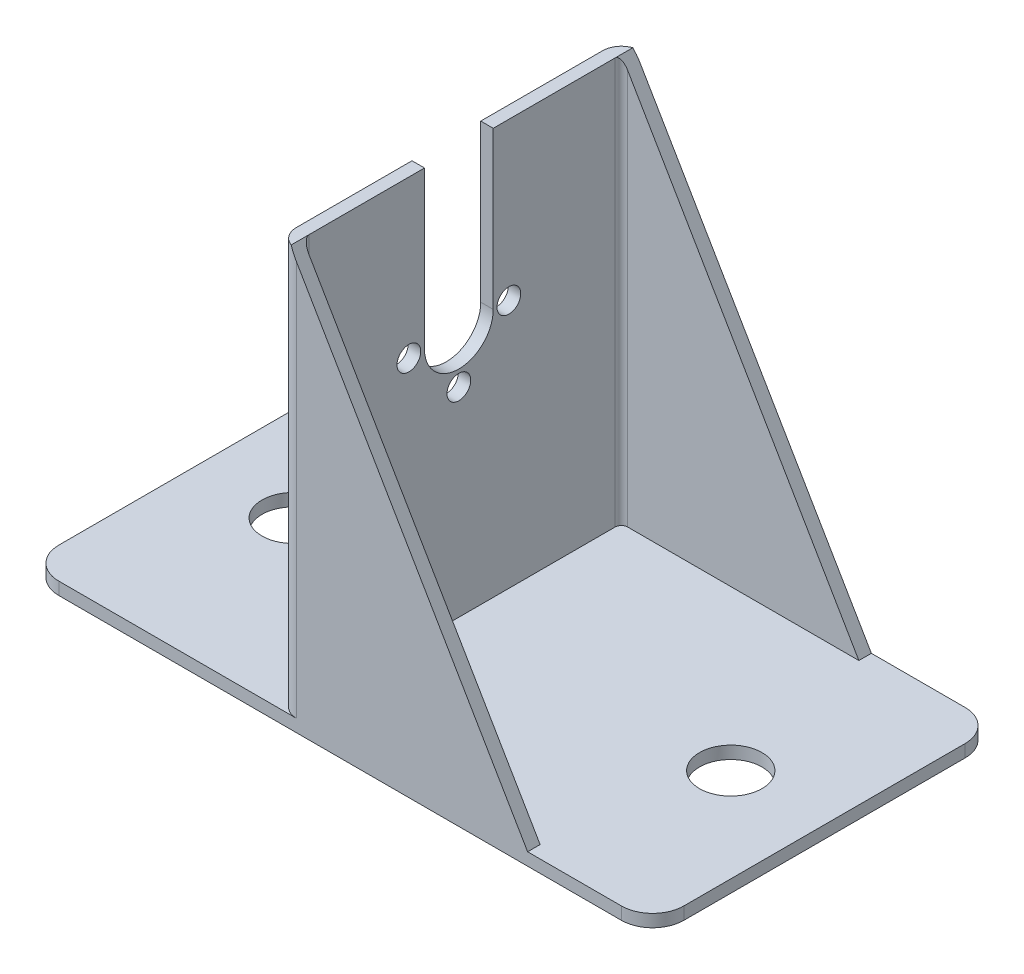
from build123d import *

# Parameters (mm, degrees)
CROQUIS1_W              = 100
CROQUIS1_H              = 55
SALIENTE_EXTRUIR1_DEPTH = 2
CROQUIS2_R              = 5
CORTAR_EXTRUIR1_DEPTH   = 2
SALIENTE_EXTRUIR2_DEPTH = 65
CORTAR_EXTRUIR2_DEPTH   = 55
REDONDEO1_R             = 5
CROQUIS6_R              = 1.9
CORTAR_EXTRUIR3_DEPTH   = 2


with BuildPart() as part:
    # Croquis1 → Saliente-Extruir1 (new body)
    with BuildSketch(Plane(origin=(0, 0, 0), x_dir=(1, 0, 0), z_dir=(0, 1, 0))):
        Rectangle(CROQUIS1_W, CROQUIS1_H)
    extrude(amount=SALIENTE_EXTRUIR1_DEPTH)

    # Croquis2 → Cortar-Extruir1 (cut)
    with BuildSketch(Plane(origin=(0, 2, 0), x_dir=(1, 0, 0), z_dir=(0, 1, 0))):
        with Locations((35, 0)):
            Circle(CROQUIS2_R)
        with Locations((-35, 0)):
            Circle(CROQUIS2_R)
    extrude(amount=-CORTAR_EXTRUIR1_DEPTH, mode=Mode.SUBTRACT)

    # Croquis3 → Saliente-Extruir2 (add)
    with BuildSketch(Plane(origin=(0, 2, 0), x_dir=(1, 0, 0), z_dir=(0, 1, 0))):
        with BuildLine():
            Line((30, 27.5), (-7, 27.5))
            ThreePointArc((-7, 27.5), (-9.121320344, 26.621320344), (-10, 24.5))
            Line((-10, 24.5), (-10, -24.5))
            ThreePointArc((-10, -24.5), (-9.121320344, -26.621320344), (-7, -27.5))
            Line((-7, -27.5), (30, -27.5))
            Line((30, -27.5), (30, -25.5))
            Line((30, -25.5), (-7, -25.5))
            ThreePointArc((-7, -25.5), (-7.707106781, -25.207106781), (-8, -24.5))
            Line((-8, -24.5), (-8, 24.5))
            ThreePointArc((-8, 24.5), (-7.707106781, 25.207106781), (-7, 25.5))
            Line((-7, 25.5), (30, 25.5))
            Line((30, 25.5), (30, 27.5))
        make_face()
    extrude(amount=SALIENTE_EXTRUIR2_DEPTH)

    # Croquis4 → Cortar-Extruir2 (cut)
    with BuildSketch(Plane.XY.offset(27.5)):
        Polygon((-8, 67), (30, 2), (30, 67), align=None)
    extrude(amount=-CORTAR_EXTRUIR2_DEPTH, mode=Mode.SUBTRACT)

    # Redondeo1
    redondeo1_edges = [part.edges().sort_by_distance(p)[0] for p in [
        (50, 1, 27.5),
        (-50, 1, 27.5),
        (-50, 1, -27.5),
        (50, 1, -27.5),
    ]]
    fillet(redondeo1_edges, radius=REDONDEO1_R)

    # Croquis6 → Cortar-Extruir3 (cut)
    with BuildSketch(Plane(origin=(-8, 0, 0), x_dir=(0, 0, -1), z_dir=(1, 0, 0))):
        with Locations((-8.5, 41.9)):
            Circle(CROQUIS6_R)
        with Locations((-0.5, 33.9)):
            Circle(CROQUIS6_R)
        with Locations((7.5, 41.9)):
            Circle(CROQUIS6_R)
        with BuildLine():
            Line((-6, 41.9), (-6, 67))
            Line((-6, 67), (5, 67))
            Line((5, 67), (5, 41.9))
            ThreePointArc((5, 41.9), (-0.5, 36.4), (-6, 41.9))
        make_face()
    extrude(amount=-CORTAR_EXTRUIR3_DEPTH, mode=Mode.SUBTRACT)


solid = part.part
